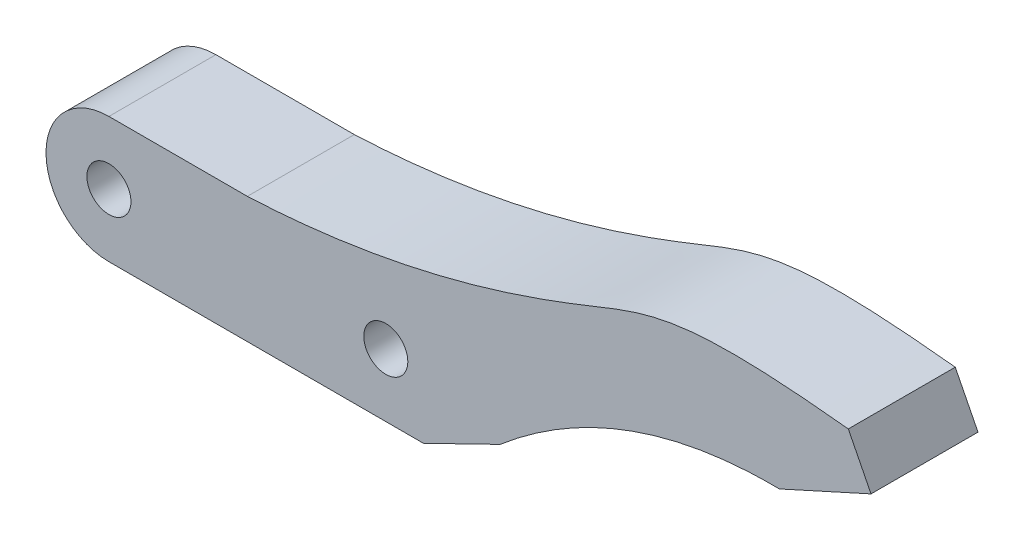
from build123d import *

# Parameters (mm, degrees)
SKETCH1_R           = 1.75
BOSS_EXTRUDE1_DEPTH = 8.5
BOSS_EXTRUDE2_DEPTH = 8.5


with BuildPart() as part:
    # Sketch1 → Boss-Extrude1 (new body)
    with BuildSketch(Plane.XY):
        with BuildLine():
            Line((22, 5), (0, 5))
            ThreePointArc((0, 5), (-5, 0), (0, -5))
            Line((0, -5), (22, -5))
            ThreePointArc((22, -5), (27, 0), (22, 5))
        make_face()
        Circle(SKETCH1_R, mode=Mode.SUBTRACT)
        with Locations((22, 0)):
            Circle(SKETCH1_R, mode=Mode.SUBTRACT)
    extrude(amount=BOSS_EXTRUDE1_DEPTH)

    # Sketch2 → Boss-Extrude2 (add)
    with BuildSketch(Plane.XY.offset(8.5)):
        with BuildLine():
            Line((22, -5), (24.99, -5))
            Line((24.99, -5), (31.08, -2.029708536))
            add(Edge.make_bspline(
                [(31.08, -2.029708536), (40.738723452, 6.188270814), (53.27, 6)],
                knots=[0, 0, 0, 1, 1, 1], degree=2))
            Line((53.27, 6), (60.557013712, 9.301428655))
            Line((60.557013712, 9.301428655), (58.75, 12.87))
            add(Edge.make_bspline(
                [(11, 5), (22.833653526, 5.523226448), (40.580841183, 11.503835096), (45.245480449, 14.322205425), (58.75, 12.87)],
                knots=[0, 0, 0, 0, 0.506898999, 1, 1, 1, 1], degree=3))
            Line((11, 5), (22, 5))
            ThreePointArc((22, 5), (27, 0), (22, -5))
        make_face()
    extrude(amount=-BOSS_EXTRUDE2_DEPTH)


solid = part.part
